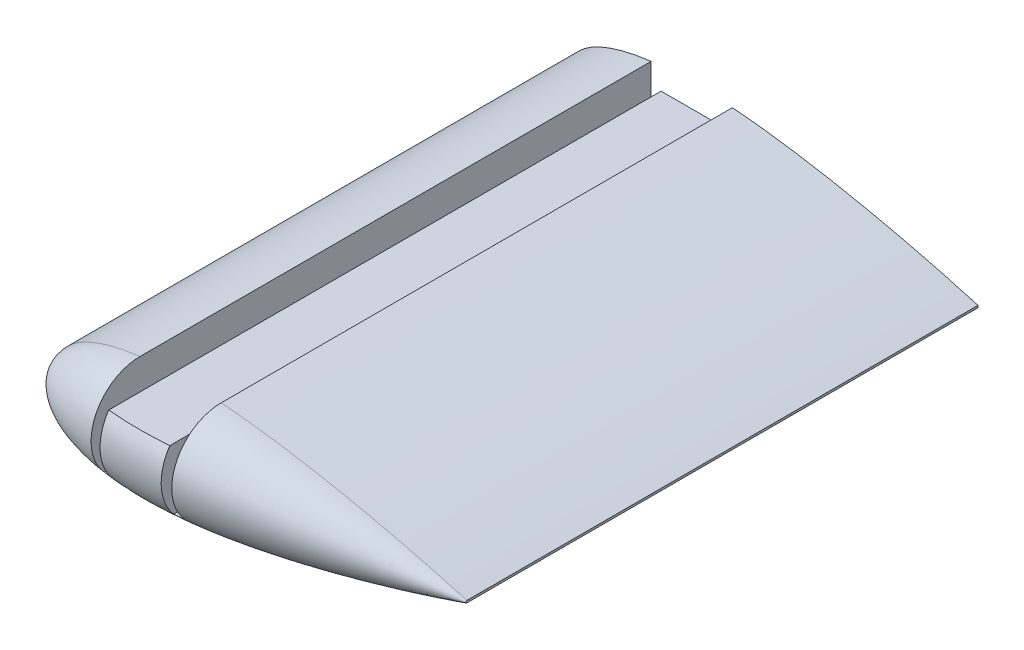
from build123d import *

# Parameters (mm, degrees)
BOSS_EXTRUDE1_DEPTH = 100
REVOLVE1_ANGLE      = 180
CUT_EXTRUDE1_REACH  = 112


with BuildPart() as part:
    # Sketch2 → Boss-Extrude1 (new body)
    with BuildSketch(Plane.XY):
        with BuildLine():
            Line((55.998991919, 0.209938863), (55.998991919, -0.209938863))
            add(Edge.make_bspline(
                [(55.998991919, 0.209938863), (53.463896497, 0.950455214), (48.803904258, 2.233873897), (42.428923908, 3.819934884), (36.743376831, 5.120873453), (31.199749362, 6.287249396), (25.282426203, 7.407488419), (20.176484373, 8.245231015), (14.979623954, 8.974887306), (10.821499069, 9.44862332), (6.697350987, 9.777022894), (3.680655604, 9.939622605), (0.739619613, 10.012665726), (-2.107751213, 9.990028944), (-4.843941705, 9.866960982), (-7.452188048, 9.640899897), (-9.916478705, 9.310630744), (-12.221751766, 8.877222993), (-14.354021752, 8.343659433), (-16.300401345, 7.714341159), (-18.049355518, 6.995399514), (-19.590605164, 6.19339349), (-20.915410238, 5.315562027), (-22.015853697, 4.368064829), (-22.884921184, 3.356491652), (-23.514451457, 2.28497611), (-23.895372624, 1.158788991), (-24.018679664, 0), (-23.895372624, -1.158788991), (-23.514451457, -2.28497611), (-22.884921184, -3.356491652), (-22.015853697, -4.368064829), (-20.915410238, -5.315562027), (-19.590605164, -6.19339349), (-18.049355518, -6.995399514), (-16.300401345, -7.714341159), (-14.354021752, -8.343659433), (-12.221751766, -8.877222993), (-9.916478705, -9.310630744), (-7.452188048, -9.640899897), (-4.843941705, -9.866960982), (-2.107751213, -9.990028944), (0.739619613, -10.012665726), (3.680655604, -9.939622605), (7.74070187, -9.72078634), (12.912832982, -9.241334238), (19.136671313, -8.415754469), (25.28242537, -7.407448977), (31.199752667, -6.287252304), (37.517160947, -4.95809922), (44.742570872, -3.275857272), (51.057566095, -1.626260629), (54.945025722, -0.517808616), (55.95791152, -0.221938691), (55.998991919, -0.209938863)],
                knots=[0, 0, 0, 0, 0.046554703, 0.085193372, 0.115793222, 0.149362634, 0.18504799, 0.221946042, 0.240561295, 0.277549679, 0.295701185, 0.31348255, 0.330796889, 0.347551895, 0.363665842, 0.379065349, 0.393686065, 0.407475418, 0.420391934, 0.432405657, 0.443502806, 0.453686421, 0.462984388, 0.471455944, 0.479204465, 0.486388269, 0.493228974, 0.5, 0.506771026, 0.513611731, 0.520795535, 0.528544056, 0.537015612, 0.546313579, 0.556497194, 0.567594343, 0.579608066, 0.592524582, 0.606313935, 0.620934651, 0.636334158, 0.652448105, 0.669203111, 0.68651745, 0.704298815, 0.740866341, 0.778053958, 0.81495201, 0.850637366, 0.884206778, 0.928744289, 0.981399281, 0.999245596, 1, 1, 1, 1], degree=3))
        make_face()
    extrude(amount=BOSS_EXTRUDE1_DEPTH)

    # Sketch4 → Revolve1 (revolve)
    with BuildSketch(Plane.XY.offset(100)):
        with BuildLine():
            Line((55.998991919, 0), (-23.977717827, 0))
            add(Edge.make_bspline(
                [(55.998991919, 0.209938863), (53.463896497, 0.950455214), (48.803904258, 2.233873897), (42.428923908, 3.819934884), (36.743376831, 5.120873453), (31.199749362, 6.287249396), (25.282426203, 7.407488419), (20.176484373, 8.245231015), (14.979623954, 8.974887306), (10.821499069, 9.44862332), (6.697350987, 9.777022894), (3.680655604, 9.939622605), (0.739619613, 10.012665726), (-2.107751213, 9.990028944), (-4.843941705, 9.866960982), (-7.452188048, 9.640899897), (-9.916478705, 9.310630744), (-12.221751766, 8.877222993), (-14.354021752, 8.343659433), (-16.300401345, 7.714341159), (-18.049355518, 6.995399514), (-19.590605164, 6.19339349), (-20.915410238, 5.315562027), (-22.015853697, 4.368064829), (-22.884921184, 3.356491652), (-23.514451457, 2.28497611), (-23.895372624, 1.158788991), (-23.977717827, 0.384942543), (-23.977717827, 0)],
                knots=[0, 0, 0, 0, 0.046554703, 0.085193372, 0.115793222, 0.149362634, 0.18504799, 0.221946042, 0.240561295, 0.277549679, 0.295701185, 0.31348255, 0.330796889, 0.347551895, 0.363665842, 0.379065349, 0.393686065, 0.407475418, 0.420391934, 0.432405657, 0.443502806, 0.453686421, 0.462984388, 0.471455944, 0.479204465, 0.486388269, 0.493228974, 0.5, 0.5, 0.5, 0.5], degree=3))
            Line((55.998991919, 0.209938863), (55.998991919, 0))
        make_face()
    revolve(axis=Axis((55.998991919, 0, 100), (1, 0, 0)), revolution_arc=REVOLVE1_ANGLE)

    # Sketch3 → Cut-Extrude1 (cut, up to next)
    with BuildSketch(Plane(origin=(0, 0, 0), x_dir=(-1, 0, 0), z_dir=(0, 0, -1)), mode=Mode.PRIVATE) as cut_extrude1_sk1:
        with BuildLine():
            Line((6, -6.5), (7.95, -6.5))
            Line((7.95, -6.5), (7.95, 9.56370057))
            add(Edge.make_bspline(
                [(-7.95, 9.673763928), (-7.525333967, 9.706496284), (-6.094337758, 9.809525273), (-3.680655604, 9.939622605), (-0.739619613, 10.012665726), (2.107751213, 9.990028944), (4.843941705, 9.866960982), (6.778071836, 9.69932668), (7.798061571, 9.581867182), (7.95, 9.56370057)],
                knots=[0.28819337, 0.28819337, 0.28819337, 0.28819337, 0.295701185, 0.31348255, 0.330796889, 0.347551895, 0.363665842, 0.379065349, 0.381762425, 0.381762425, 0.381762425, 0.381762425], degree=3))
            Line((-7.95, 9.673763928), (-7.95, -6.5))
            Line((-7.95, -6.5), (-6, -6.5))
            Line((-6, -6.5), (-6, 5.5))
            Line((-6, 5.5), (6, 5.5))
            Line((6, 5.5), (6, -6.5))
        make_face()
    cut_extrude1_tool1 = extrude(cut_extrude1_sk1.sketch, amount=-CUT_EXTRUDE1_REACH, mode=Mode.PRIVATE) & part.part
    add(cut_extrude1_tool1.solids().sort_by_distance((-6.975, -6.270858, 0))[0], mode=Mode.SUBTRACT)


solid = part.part
